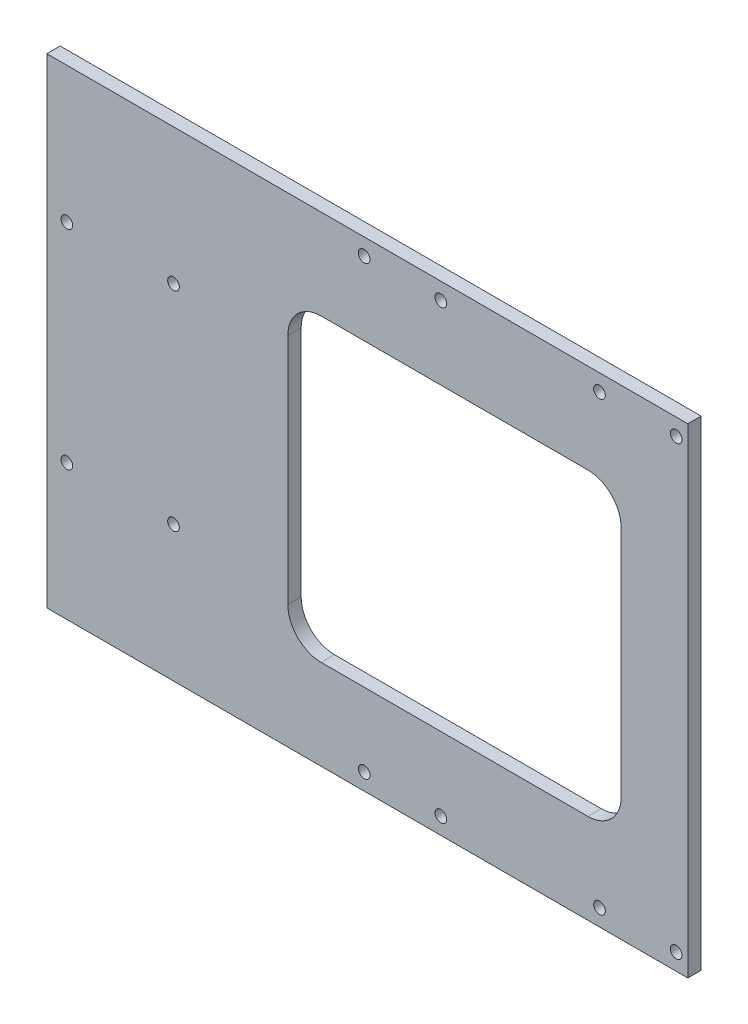
from build123d import *

# Parameters (mm, degrees)
SKETCH_1_W          = 192.3
SKETCH_1_H          = 144
SKETCH_1_R          = 1.75
EXTRUDE_1_DEPTH     = 4
SKETCH_2_W          = 100
SKETCH_2_H          = 90
CUT_EXTRUDE_1_DEPTH = 10
FILLET_1_R          = 10


with BuildPart() as part:
    # ｽｹｯﾁ1 → ﾎﾞｽ - 押し出し1 (new body)
    with BuildSketch(Plane.XY):
        Rectangle(SKETCH_1_W, SKETCH_1_H)
        with Locations((92.65, 67)):
            Circle(SKETCH_1_R, mode=Mode.SUBTRACT)
        with Locations((69.65, 67)):
            Circle(SKETCH_1_R, mode=Mode.SUBTRACT)
        with Locations((22.05, 67)):
            Circle(SKETCH_1_R, mode=Mode.SUBTRACT)
        with Locations((-0.95, 67)):
            Circle(SKETCH_1_R, mode=Mode.SUBTRACT)
        with Locations((-0.95, -67)):
            Circle(SKETCH_1_R, mode=Mode.SUBTRACT)
        with Locations((22.05, -67)):
            Circle(SKETCH_1_R, mode=Mode.SUBTRACT)
        with Locations((69.65, -67)):
            Circle(SKETCH_1_R, mode=Mode.SUBTRACT)
        with Locations((92.65, -67)):
            Circle(SKETCH_1_R, mode=Mode.SUBTRACT)
        with Locations((-90.15, 31.25)):
            Circle(SKETCH_1_R, mode=Mode.SUBTRACT)
        with Locations((-90.15, -31.25)):
            Circle(SKETCH_1_R, mode=Mode.SUBTRACT)
        with Locations((-58.15, 31.25)):
            Circle(SKETCH_1_R, mode=Mode.SUBTRACT)
        with Locations((-58.15, -31.25)):
            Circle(SKETCH_1_R, mode=Mode.SUBTRACT)
    extrude(amount=EXTRUDE_1_DEPTH)

    # ｽｹｯﾁ2 → ｶｯﾄ - 押し出し1 (cut)
    with BuildSketch(Plane.XY.offset(4)):
        with Locations((26.15, 0)):
            Rectangle(SKETCH_2_W, SKETCH_2_H)
    extrude(amount=-CUT_EXTRUDE_1_DEPTH, mode=Mode.SUBTRACT)

    # ﾌｨﾚｯﾄ1
    fillet_1_edges = [part.edges().sort_by_distance(p)[0] for p in [
        (-23.85, -45, 2),
        (-23.85, 45, 2),
        (76.15, 45, 2),
        (76.15, -45, 2),
    ]]
    fillet(fillet_1_edges, radius=FILLET_1_R)


solid = part.part
